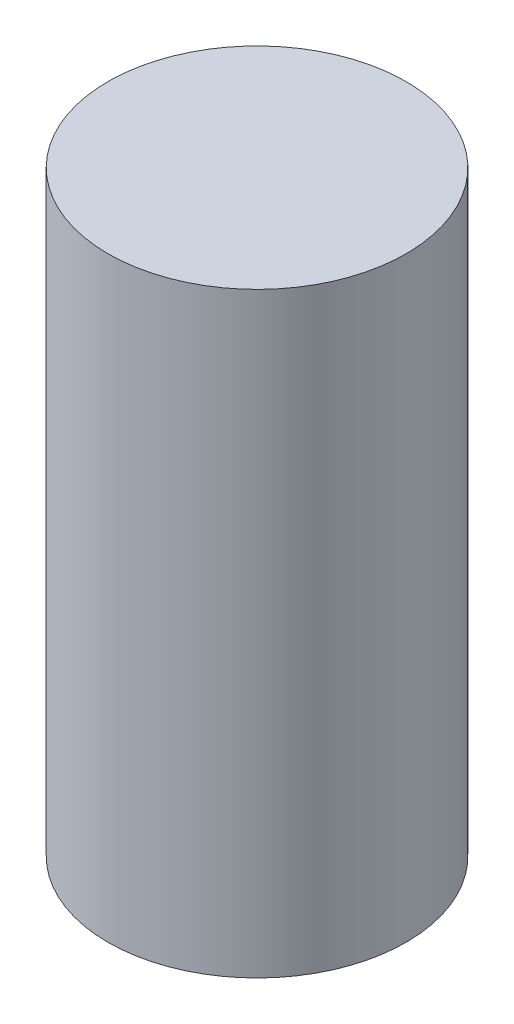
from build123d import *

# Parameters (mm, degrees)
CROQUIS1_R              = 2
SALIENTE_EXTRUIR1_DEPTH = 8


with BuildPart() as part:
    # Croquis1 → Saliente-Extruir1 (new body)
    with BuildSketch(Plane(origin=(0, 0, 0), x_dir=(1, 0, 0), z_dir=(0, 1, 0))):
        Circle(CROQUIS1_R)
    extrude(amount=SALIENTE_EXTRUIR1_DEPTH)


solid = part.part
